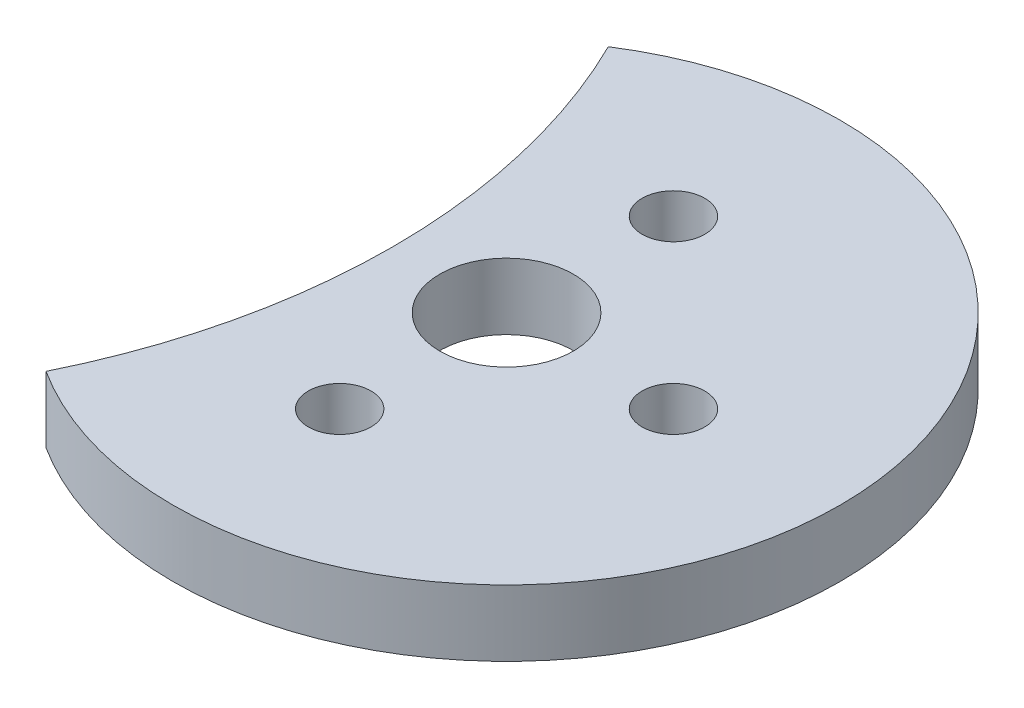
from build123d import *

# Parameters (mm, degrees)
SKETCH1_R           = 15.988284
BOSS_EXTRUDE1_DEPTH = 3.175
SKETCH2_R           = 30.48
CUT_EXTRUDE1_DEPTH  = 4.175
SKETCH4_R           = 1.499997
SKETCH4_R_2         = 3.2004
CUT_EXTRUDE2_DEPTH  = 4.175


with BuildPart() as part:
    # Sketch1 → Boss-Extrude1 (new body)
    with BuildSketch(Plane(origin=(0, 0, 0), x_dir=(1, 0, 0), z_dir=(0, 1, 0))):
        Circle(SKETCH1_R)
    extrude(amount=BOSS_EXTRUDE1_DEPTH)

    # Sketch2 → Cut-Extrude1 (cut, through all)
    with BuildSketch(Plane(origin=(0, 3.175, 0), x_dir=(1, 0, 0), z_dir=(0, 1, 0))):
        with Locations((-35.938985022, 0)):
            Circle(SKETCH2_R)
    extrude(amount=-CUT_EXTRUDE1_DEPTH, mode=Mode.SUBTRACT)

    # Sketch4 → Cut-Extrude2 (cut, through all)
    with BuildSketch(Plane(origin=(0, 3.175, 0), x_dir=(1, 0, 0), z_dir=(0, 1, 0))):
        with Locations((0, 7.999984)):
            Circle(SKETCH4_R)
        with Locations((0, -7.999984)):
            Circle(SKETCH4_R)
        with Locations((7.999984, 0)):
            Circle(SKETCH4_R)
        Circle(SKETCH4_R_2)
    extrude(amount=-CUT_EXTRUDE2_DEPTH, mode=Mode.SUBTRACT)


solid = part.part
